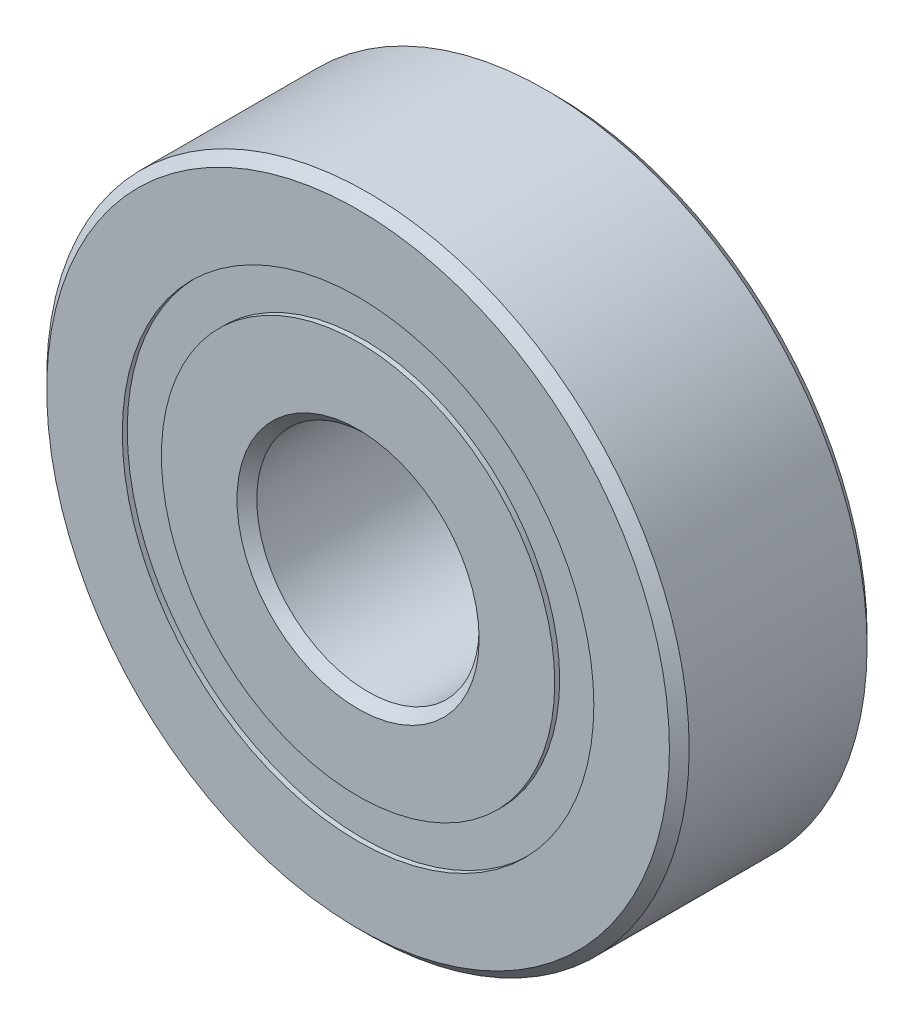
from build123d import *

# Parameters (mm, degrees)
CIRPATTERN1_COUNT = 12
SKETCH5_W         = 1.854105558
SKETCH5_H         = 1.582417582


with BuildPart() as part:
    # Sketch1 → Revolve1 (revolve)
    with BuildSketch(Plane(origin=(0, 0, 0), x_dir=(0, 0, -1), z_dir=(1, 0, 0))):
        with BuildLine():
            Line((3.6, 13), (-3.6, 13))
            Line((-3.6, 13), (-4, 12.6))
            Line((-4, 12.6), (-4, 9.541208791))
            Line((-4, 9.541208791), (-1.777777778, 9.541208791))
            ThreePointArc((-1.777777778, 9.541208791), (0, 10.695894442), (1.777777778, 9.541208791))
            Line((1.777777778, 9.541208791), (4, 9.541208791))
            Line((4, 9.541208791), (4, 12.6))
            Line((4, 12.6), (3.6, 13))
        make_face()
    revolve(axis=Axis((0, 0, 4), (0, 0, -1)))


with BuildPart() as body_2:
    # Sketch3 → Revolve3 (revolve)
    with BuildSketch(Plane(origin=(0, 0, 0), x_dir=(0, 0, -1), z_dir=(1, 0, 0))):
        with BuildLine():
            Line((-4, 7.958791209), (-1.777777778, 7.958791209))
            ThreePointArc((-1.777777778, 7.958791209), (0, 6.804105558), (1.777777778, 7.958791209))
            Line((1.777777778, 7.958791209), (4, 7.958791209))
            Line((4, 7.958791209), (4, 4.9))
            Line((4, 4.9), (3.6, 4.5))
            Line((3.6, 4.5), (-3.6, 4.5))
            Line((-3.6, 4.5), (-4, 4.9))
            Line((-4, 4.9), (-4, 7.958791209))
        make_face()
    revolve(axis=Axis((0, 0, 4), (0, 0, -1)))


with BuildPart() as body_3:
    # Sketch4 → Revolve4 (revolve)
    with BuildSketch(Plane(origin=(0, 0, 0), x_dir=(0, 0, -1), z_dir=(1, 0, 0))):
        with BuildLine():
            Line((-1.945894442, 8.75), (1.945894442, 8.75))
            ThreePointArc((1.945894442, 8.75), (0, 10.695894442), (-1.945894442, 8.75))
        make_face()
    revolve(axis=Axis((0, 8.75, 1.945894442), (0, 0, -1)))


with BuildPart() as cirpattern1_1:
    # CirPattern1: pattern copy
    add(body_3.part.rotate(Axis((0, 0, -4), (0, 0, 1)), 1 * 360 / CIRPATTERN1_COUNT))


with BuildPart() as cirpattern1_2:
    # CirPattern1: pattern copy
    add(body_3.part.rotate(Axis((0, 0, -4), (0, 0, 1)), 2 * 360 / CIRPATTERN1_COUNT))


with BuildPart() as cirpattern1_3:
    # CirPattern1: pattern copy
    add(body_3.part.rotate(Axis((0, 0, -4), (0, 0, 1)), 3 * 360 / CIRPATTERN1_COUNT))


with BuildPart() as cirpattern1_4:
    # CirPattern1: pattern copy
    add(body_3.part.rotate(Axis((0, 0, -4), (0, 0, 1)), 4 * 360 / CIRPATTERN1_COUNT))


with BuildPart() as cirpattern1_5:
    # CirPattern1: pattern copy
    add(body_3.part.rotate(Axis((0, 0, -4), (0, 0, 1)), 5 * 360 / CIRPATTERN1_COUNT))


with BuildPart() as cirpattern1_6:
    # CirPattern1: pattern copy
    add(body_3.part.rotate(Axis((0, 0, -4), (0, 0, 1)), 6 * 360 / CIRPATTERN1_COUNT))


with BuildPart() as cirpattern1_7:
    # CirPattern1: pattern copy
    add(body_3.part.rotate(Axis((0, 0, -4), (0, 0, 1)), 7 * 360 / CIRPATTERN1_COUNT))


with BuildPart() as cirpattern1_8:
    # CirPattern1: pattern copy
    add(body_3.part.rotate(Axis((0, 0, -4), (0, 0, 1)), 8 * 360 / CIRPATTERN1_COUNT))


with BuildPart() as cirpattern1_9:
    # CirPattern1: pattern copy
    add(body_3.part.rotate(Axis((0, 0, -4), (0, 0, 1)), 9 * 360 / CIRPATTERN1_COUNT))


with BuildPart() as cirpattern1_10:
    # CirPattern1: pattern copy
    add(body_3.part.rotate(Axis((0, 0, -4), (0, 0, 1)), 10 * 360 / CIRPATTERN1_COUNT))


with BuildPart() as cirpattern1_11:
    # CirPattern1: pattern copy
    add(body_3.part.rotate(Axis((0, 0, -4), (0, 0, 1)), 11 * 360 / CIRPATTERN1_COUNT))


with BuildPart() as body_15:
    # Sketch5 → Revolve5 (revolve)
    with BuildSketch(Plane(origin=(0, 0, 0), x_dir=(0, 0, -1), z_dir=(1, 0, 0))):
        with Locations((-2.872947221, 8.75)):
            Rectangle(SKETCH5_W, SKETCH5_H)
        with Locations((2.872947221, 8.75)):
            Rectangle(SKETCH5_W, SKETCH5_H)
    revolve(axis=Axis((0, 0, 4), (0, 0, -1)))


solid = Compound([part.part, body_2.part, body_3.part, cirpattern1_1.part, cirpattern1_2.part, cirpattern1_3.part, cirpattern1_4.part, cirpattern1_5.part, cirpattern1_6.part, cirpattern1_7.part, cirpattern1_8.part, cirpattern1_9.part, cirpattern1_10.part, cirpattern1_11.part, body_15.part])
